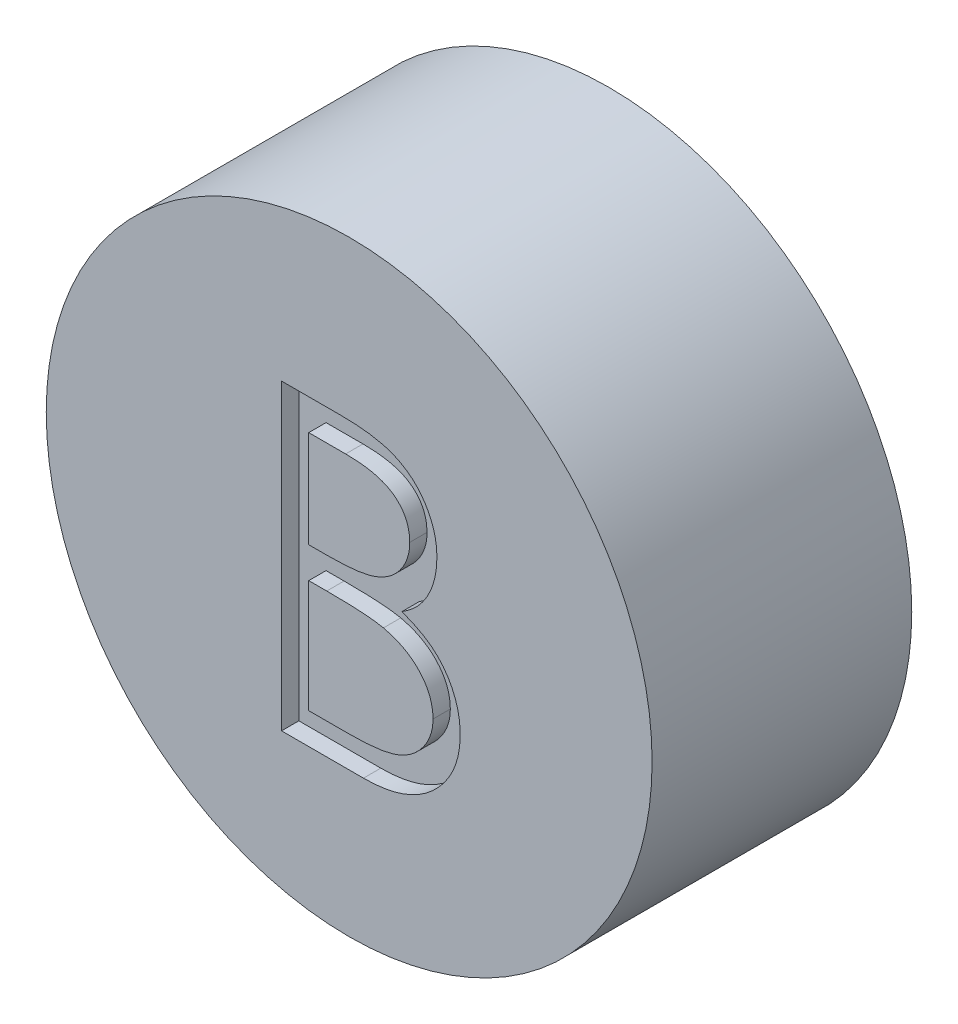
from build123d import *

# Parameters (mm, degrees)
SKETCH1_R           = 3.5
BOSS_EXTRUDE1_DEPTH = 3
CUT_EXTRUDE1_DEPTH  = 0.2


with BuildPart() as part:
    # Sketch1 → Boss-Extrude1 (new body)
    with BuildSketch(Plane.XY):
        Circle(SKETCH1_R)
    extrude(amount=BOSS_EXTRUDE1_DEPTH)

    # Sketch2 → Cut-Extrude1 (cut)
    with BuildSketch(Plane.XY.offset(3)):
        with BuildLine():
            Line((-0.781290974, 1.669629579), (-0.098398346, 1.669629579))
            add(Edge.make_bspline(
                [(-0.098398346, 1.669629579), (-0.064969868, 1.669453828), (-0.000177158, 1.66911318), (0.094042284, 1.663830049), (0.182291095, 1.656626379), (0.264594867, 1.645196287), (0.34091557, 1.63140451), (0.411483207, 1.614702693), (0.476073379, 1.59467608), (0.553186116, 1.562829799), (0.641106776, 1.51550663), (0.736305169, 1.445578065), (0.817709408, 1.360045602), (0.887895726, 1.263562947), (0.943696845, 1.157427175), (0.984066143, 1.044167986), (1.009624018, 0.925246244), (1.012252452, 0.843603066), (1.013580821, 0.802341919)],
                knots=[0, 0, 0, 0, 0.00010027, 0.000194349, 0.000283026, 0.000365821, 0.000443519, 0.000515622, 0.000583254, 0.00064614, 0.000765662, 0.000881909, 0.000998927, 0.001118415, 0.001238844, 0.00135727, 0.001478274, 0.001601912, 0.001601912, 0.001601912, 0.001601912], degree=3))
            add(Edge.make_bspline(
                [(1.013580821, 0.802341919), (1.012487602, 0.763689363), (1.010339325, 0.687733446), (0.989796565, 0.576639337), (0.957635897, 0.470888118), (0.912930648, 0.370865732), (0.854828652, 0.278832119), (0.785970333, 0.194044853), (0.70289353, 0.120093796), (0.64065029, 0.078750894), (0.609033545, 0.057750572)],
                knots=[0, 0, 0, 0, 0.000115857, 0.00022767, 0.000337672, 0.000446877, 0.000555233, 0.000663318, 0.000773539, 0.000887324, 0.000887324, 0.000887324, 0.000887324], degree=3))
            add(Edge.make_bspline(
                [(0.609033545, 0.057750572), (0.648793972, 0.042485573), (0.72486552, 0.013279849), (0.829551532, -0.038355615), (0.919746377, -0.094517725), (0.996143523, -0.155849575), (1.061481178, -0.221958386), (1.11853412, -0.293813501), (1.167215494, -0.372352258), (1.208928417, -0.456755794), (1.241477174, -0.546162262), (1.265853078, -0.639733038), (1.279820527, -0.737132593), (1.281808168, -0.803417973), (1.28281159, -0.836880838)],
                knots=[0, 0, 0, 0, 0.000127722, 0.000244363, 0.000349599, 0.000445847, 0.000537565, 0.000627901, 0.000720503, 0.000814257, 0.000909859, 0.001005428, 0.001103887, 0.001204268, 0.001204268, 0.001204268, 0.001204268], degree=3))
            add(Edge.make_bspline(
                [(1.28281159, -0.836880838), (1.281834744, -0.87104771), (1.279912772, -0.938271988), (1.2657328, -1.037027123), (1.241723693, -1.131402069), (1.208652547, -1.222007252), (1.165490232, -1.308667386), (1.112962268, -1.39148065), (1.050330704, -1.469614981), (0.980267835, -1.543938604), (0.90100569, -1.610766391), (0.815489935, -1.670282098), (0.722643615, -1.71922816), (0.623991621, -1.760344182), (0.518427305, -1.79175138), (0.406424697, -1.813723954), (0.288080396, -1.828528991), (0.206870644, -1.829746196), (0.165223449, -1.830370421)],
                knots=[0, 0, 0, 0, 0.000102481, 0.000201635, 0.000298562, 0.000394165, 0.000490425, 0.000588455, 0.000687769, 0.000790423, 0.000894381, 0.000998232, 0.001102369, 0.001208616, 0.001318415, 0.001432129, 0.001550749, 0.00167562, 0.00167562, 0.00167562, 0.00167562], degree=3))
            Line((0.165223449, -1.830370421), (-0.781290974, -1.830370421))
            Line((-0.781290974, -1.830370421), (-0.781290974, 1.669629579))
        make_face()
        with BuildLine():
            Line((-0.46718841, 1.31065522), (-0.46718841, 0.188860348))
            Line((-0.46718841, 0.188860348), (-0.25615075, 0.188860348))
            add(Edge.make_bspline(
                [(-0.25615075, 0.188860348), (-0.225301955, 0.189260271), (-0.165695795, 0.190033004), (-0.079375899, 0.192246521), (0.000749119, 0.198444564), (0.074540952, 0.204640826), (0.141883396, 0.214715414), (0.202627258, 0.226707537), (0.257725855, 0.239390442), (0.3212654, 0.260959929), (0.393338349, 0.292837604), (0.470171453, 0.34230944), (0.537905923, 0.401233793), (0.59510311, 0.469224755), (0.641914581, 0.544090941), (0.674428296, 0.624637821), (0.69647558, 0.708857953), (0.698467112, 0.766676206), (0.699478256, 0.796031822)],
                knots=[0, 0, 0, 0, 9.2559e-05, 0.000178842, 0.000258967, 0.000333616, 0.000400942, 0.000463093, 0.000519379, 0.000570374, 0.000664201, 0.000755025, 0.000843472, 0.000932526, 0.001020669, 0.001107124, 0.001192318, 0.001280185, 0.001280185, 0.001280185, 0.001280185], degree=3))
            add(Edge.make_bspline(
                [(0.699478256, 0.796031822), (0.698952076, 0.815457594), (0.697919916, 0.853563366), (0.689466614, 0.90911272), (0.675099039, 0.961356473), (0.656644746, 1.011010583), (0.630856057, 1.056522433), (0.600492594, 1.099465629), (0.563806904, 1.138377747), (0.522049591, 1.174747246), (0.474040968, 1.206991774), (0.419809676, 1.235232537), (0.358621999, 1.257973313), (0.291509144, 1.277889466), (0.217438057, 1.29187776), (0.137263503, 1.303531147), (0.050328784, 1.309463889), (-0.009816318, 1.310249252), (-0.040906359, 1.31065522)],
                knots=[0, 0, 0, 0, 5.8261e-05, 0.000114285, 0.000168029, 0.000220632, 0.000272728, 0.000324483, 0.000378062, 0.000432741, 0.000490301, 0.000551137, 0.000615721, 0.000685833, 0.000760908, 0.00084162, 0.000928788, 0.00102206, 0.00102206, 0.00102206, 0.00102206], degree=3))
            Line((-0.040906359, 1.31065522), (-0.46718841, 1.31065522))
        make_face(mode=Mode.SUBTRACT)
        with BuildLine():
            Line((-0.46718841, -0.170114011), (-0.46718841, -1.471396062))
            Line((-0.46718841, -1.471396062), (-0.019872705, -1.471396062))
            add(Edge.make_bspline(
                [(-0.019872705, -1.471396062), (0.012146221, -1.471012315), (0.073858479, -1.470272692), (0.16295971, -1.467858138), (0.245542813, -1.462365862), (0.321230949, -1.453720012), (0.390841402, -1.444341563), (0.453539105, -1.431730282), (0.509832298, -1.417281322), (0.575106606, -1.39494715), (0.648610114, -1.360250679), (0.727820971, -1.307936452), (0.798247189, -1.245613144), (0.858052448, -1.17348223), (0.907065436, -1.095050903), (0.942720892, -1.011905553), (0.964711748, -0.925420026), (0.967373918, -0.866453313), (0.968709026, -0.836880838)],
                knots=[0, 0, 0, 0, 9.6064e-05, 0.000185151, 0.000267373, 0.000344257, 0.000413665, 0.000478015, 0.000536005, 0.000587888, 0.000684801, 0.000778918, 0.000871787, 0.000965866, 0.001059062, 0.00114827, 0.001236355, 0.001324974, 0.001324974, 0.001324974, 0.001324974], degree=3))
            add(Edge.make_bspline(
                [(0.968709026, -0.836880838), (0.968432921, -0.818387497), (0.967885166, -0.781699116), (0.959624551, -0.727783296), (0.947610682, -0.675557423), (0.932079248, -0.624879683), (0.909459781, -0.576666306), (0.883053236, -0.529963747), (0.852091834, -0.484710267), (0.803847668, -0.427498014), (0.733675683, -0.361581001), (0.633968908, -0.297043499), (0.52059661, -0.244995692), (0.438369117, -0.222896215), (0.395892519, -0.211480197)],
                knots=[0, 0, 0, 0, 5.5429e-05, 0.000109963, 0.000163198, 0.000216191, 0.000268588, 0.000322593, 0.000377046, 0.000432793, 0.000546889, 0.000664343, 0.000787646, 0.000919405, 0.000919405, 0.000919405, 0.000919405], degree=3))
            add(Edge.make_bspline(
                [(0.395892519, -0.211480197), (0.378863423, -0.208025113), (0.341940831, -0.200533778), (0.281733251, -0.192626075), (0.212997382, -0.185581015), (0.135574504, -0.180369857), (0.049366663, -0.174983314), (-0.045810255, -0.172888493), (-0.14956757, -0.170389233), (-0.221559942, -0.170208098), (-0.258955237, -0.170114011)],
                knots=[0, 0, 0, 0, 5.2115e-05, 0.000112995, 0.000182062, 0.000259389, 0.000345767, 0.00044116, 0.000544948, 0.000657129, 0.000657129, 0.000657129, 0.000657129], degree=3))
            Line((-0.258955237, -0.170114011), (-0.46718841, -0.170114011))
        make_face(mode=Mode.SUBTRACT)
    extrude(amount=-CUT_EXTRUDE1_DEPTH, mode=Mode.SUBTRACT)


solid = part.part
